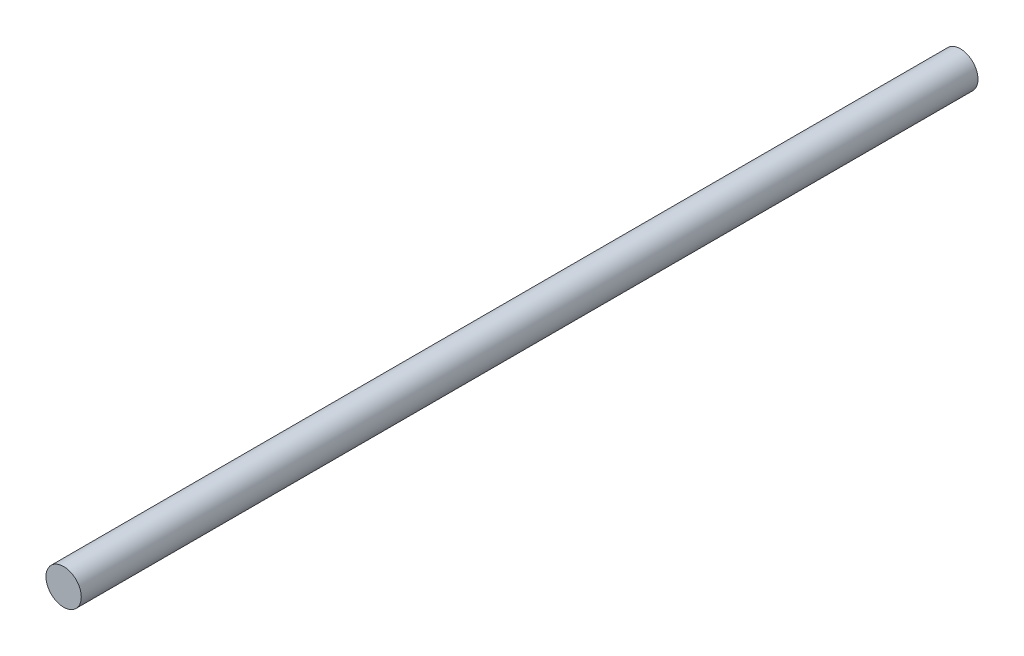
from build123d import *

# Parameters (mm, degrees)
SKETCH1_R           = 6.35
BOSS_EXTRUDE1_DEPTH = 322.58


with BuildPart() as part:
    # Sketch1 → Boss-Extrude1 (new body)
    with BuildSketch(Plane.XY):
        Circle(SKETCH1_R)
    extrude(amount=BOSS_EXTRUDE1_DEPTH)


solid = part.part
